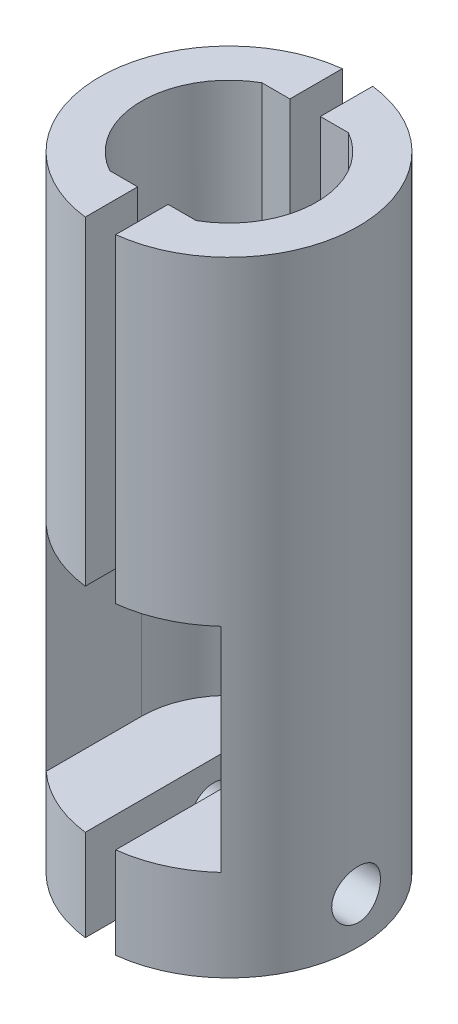
from build123d import *

# Parameters (mm, degrees)
EXTRUDE_1_DEPTH          = 21
EXTRUDE_1_2_DEPTH        = 21
EXTRUDE_2_DEPTH          = 14
EXTRUDE_3_DEPTH          = 6
SKETCH_6_R               = 1.6
CUT_EXTRUDE_1_DEPTH      = 9.5
CUT_EXTRUDE_1_DEPTH_BACK = 9.5


with BuildPart() as part:
    # Эскиз1 → Бобышка-Вытянуть1 (new body)
    with BuildSketch(Plane(origin=(0, 0, 0), x_dir=(1, 0, 0), z_dir=(0, 1, 0))):
        with BuildLine():
            Line((2.839454173, 5), (1, 5))
            Line((1, 5), (1, 8.440971508))
            ThreePointArc((1, 8.440971508), (8.5, 0), (1, -8.440971508))
            Line((1, -8.440971508), (1, -5))
            Line((1, -5), (2.839454173, -5))
            ThreePointArc((2.839454173, -5), (5.75, 0), (2.839454173, 5))
        make_face()
    extrude(amount=EXTRUDE_1_DEPTH)



with BuildPart() as body_2:
    # Эскиз1 → Extrude 1 2 (new body)
    with BuildSketch(Plane(origin=(0, 0, 0), x_dir=(1, 0, 0), z_dir=(0, 1, 0))):
        with BuildLine():
            Line((-1, 8.440971508), (-1, 5))
            Line((-1, 5), (-2.839454173, 5))
            ThreePointArc((-2.839454173, 5), (-5.75, 0), (-2.839454173, -5))
            Line((-2.839454173, -5), (-1, -5))
            Line((-1, -5), (-1, -8.440971508))
            ThreePointArc((-1, -8.440971508), (-8.5, 0), (-1, 8.440971508))
        make_face()
    extrude(amount=EXTRUDE_1_2_DEPTH)


with BuildPart() as part_1:
    add(part.part)

    add(body_2.part)  # Бобышка-Вытянуть2 merges body 2
    # Эскиз3 → Бобышка-Вытянуть2 (add)
    with BuildSketch(Plane.XZ):
        with BuildLine():
            Line((1, -8.440971508), (1, -5))
            Line((1, -5), (2.839454173, -5))
            ThreePointArc((2.839454173, -5), (4.969374281, -2.892718316), (5.75, 0))
            Line((5.75, 0), (5.75, 6.259992013))
            ThreePointArc((5.75, 6.259992013), (8.088275905, -2.613387245), (1, -8.440971508))
        make_face()
        with BuildLine():
            Line((-2.839454173, -5), (-1, -5))
            Line((-1, -5), (-1, -8.440971508))
            ThreePointArc((-1, -8.440971508), (-8.088275905, -2.613387245), (-5.75, 6.259992013))
            Line((-5.75, 6.259992013), (-5.75, 0))
            ThreePointArc((-5.75, 0), (-4.969374281, -2.892718316), (-2.839454173, -5))
        make_face()
    extrude(amount=EXTRUDE_2_DEPTH)

    # Эскиз4 → Бобышка-Вытянуть3 (add)
    with BuildSketch(Plane.XZ.offset(14)):
        with BuildLine():
            Line((-1, 8.440971508), (-1, -8.440971508))
            ThreePointArc((-1, -8.440971508), (-8.5, 0), (-1, 8.440971508))
        make_face()
        with BuildLine():
            Line((1, 8.440971508), (1, -8.440971508))
            ThreePointArc((1, -8.440971508), (8.5, 0), (1, 8.440971508))
        make_face()
    extrude(amount=EXTRUDE_3_DEPTH)

    # Эскиз6 → Вырез-Вытянуть1 (cut, two sides)
    with BuildSketch(Plane(origin=(0, 0, 0), x_dir=(0, 0, -1), z_dir=(1, 0, 0))) as cut_extrude_1_sk:
        with Locations((0, -17)):
            Circle(SKETCH_6_R)
    extrude(amount=CUT_EXTRUDE_1_DEPTH, mode=Mode.SUBTRACT)
    extrude(cut_extrude_1_sk.sketch, amount=-CUT_EXTRUDE_1_DEPTH_BACK, mode=Mode.SUBTRACT)


solid = part_1.part
